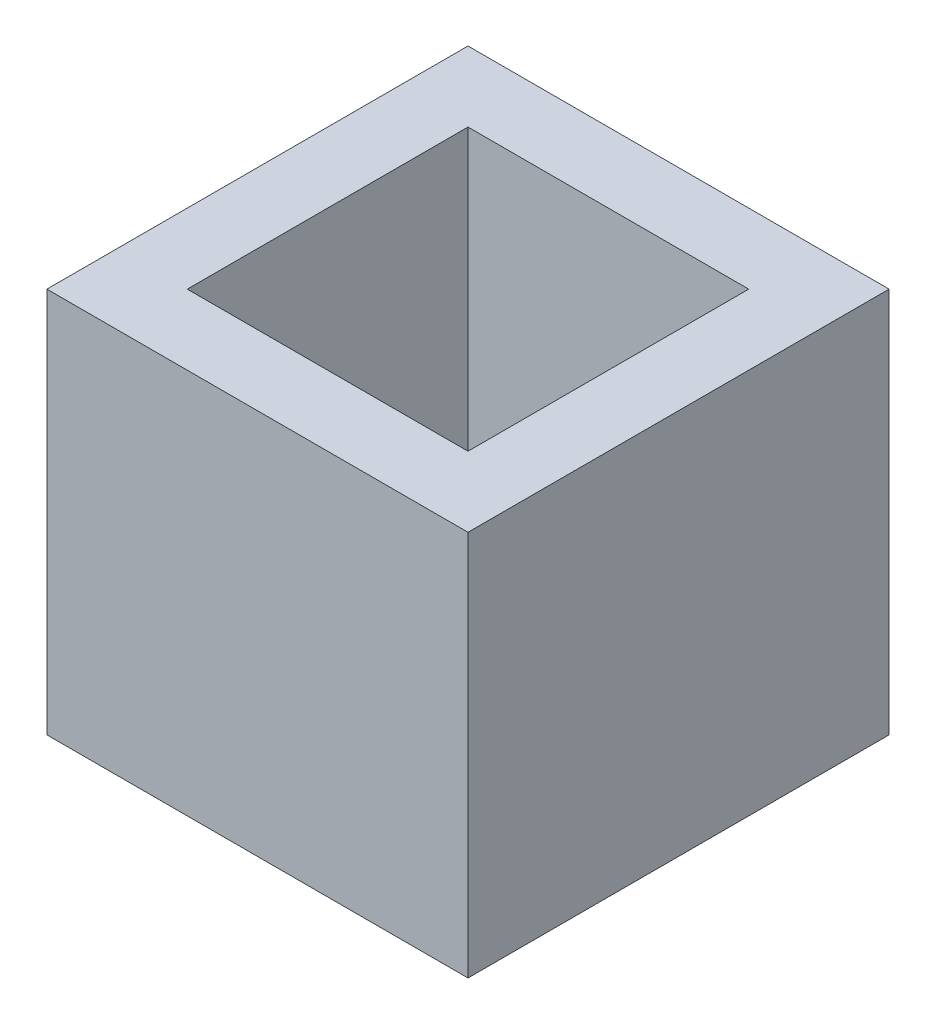
from build123d import *

# Parameters (mm, degrees)
SKETCH1_W           = 12
SKETCH1_H           = 12
BOSS_EXTRUDE1_DEPTH = 11
SHELL1_T            = -2
SKETCH3_R           = 0.625
CUT_EXTRUDE1_DEPTH  = 10


with BuildPart() as part:
    # Sketch1 → Boss-Extrude1 (new body)
    with BuildSketch(Plane(origin=(0, 0, 0), x_dir=(1, 0, 0), z_dir=(0, 1, 0))):
        with Locations((6, 6)):
            Rectangle(SKETCH1_W, SKETCH1_H)
    extrude(amount=BOSS_EXTRUDE1_DEPTH)

    # Shell1
    shell1_openings = [part.faces().sort_by_distance(p)[0] for p in [
        (6, 11, -6),
    ]]
    offset(amount=SHELL1_T, openings=shell1_openings, kind=Kind.INTERSECTION)

    # Sketch3 → Cut-Extrude1 (cut)
    with BuildSketch(Plane.XZ):
        with Locations((6, -4.73)):
            Circle(SKETCH3_R)
        with Locations((6, -7.27)):
            Circle(SKETCH3_R)
    extrude(amount=-CUT_EXTRUDE1_DEPTH, mode=Mode.SUBTRACT)


solid = part.part
